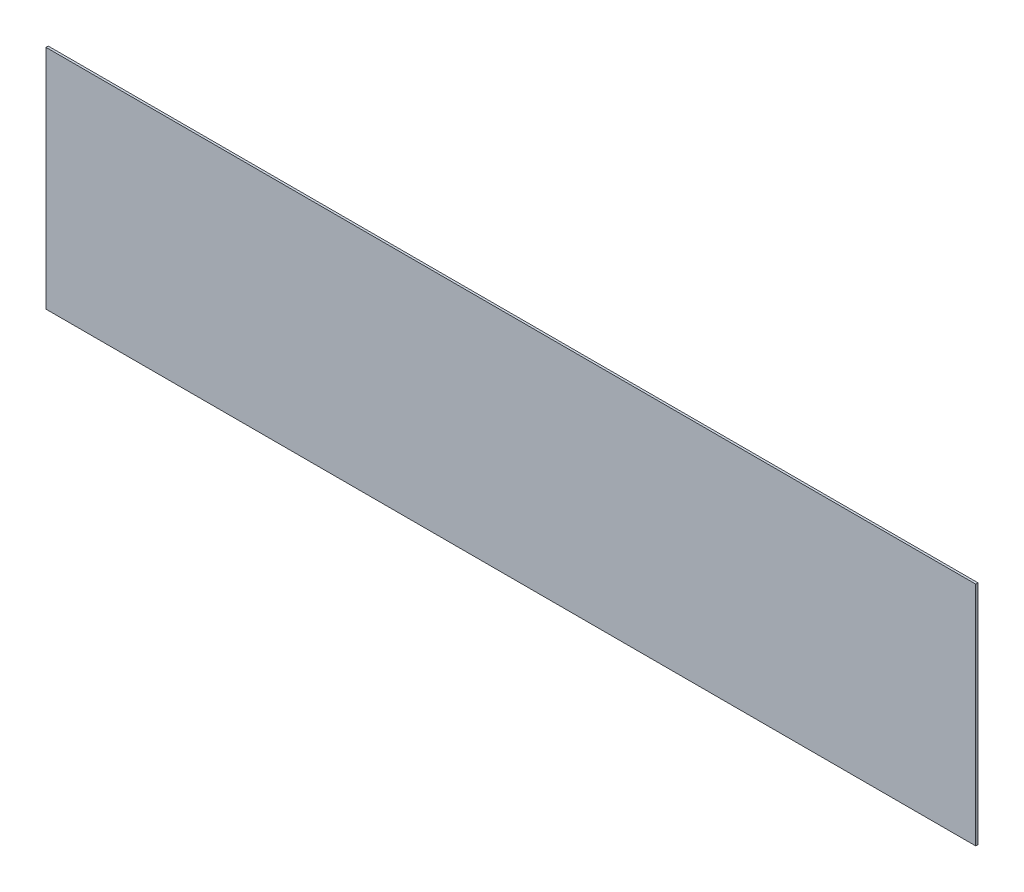
from build123d import *

# Parameters (mm, degrees)
ESBO_O1_W                = 1640
ESBO_O1_H                = 400
RESSALTO_EXTRUS_O1_DEPTH = 4


with BuildPart() as part:
    # Esboço1 → Ressalto-extrusão1 (new body)
    with BuildSketch(Plane.XY):
        Rectangle(ESBO_O1_W, ESBO_O1_H)
    extrude(amount=RESSALTO_EXTRUS_O1_DEPTH)


solid = part.part
